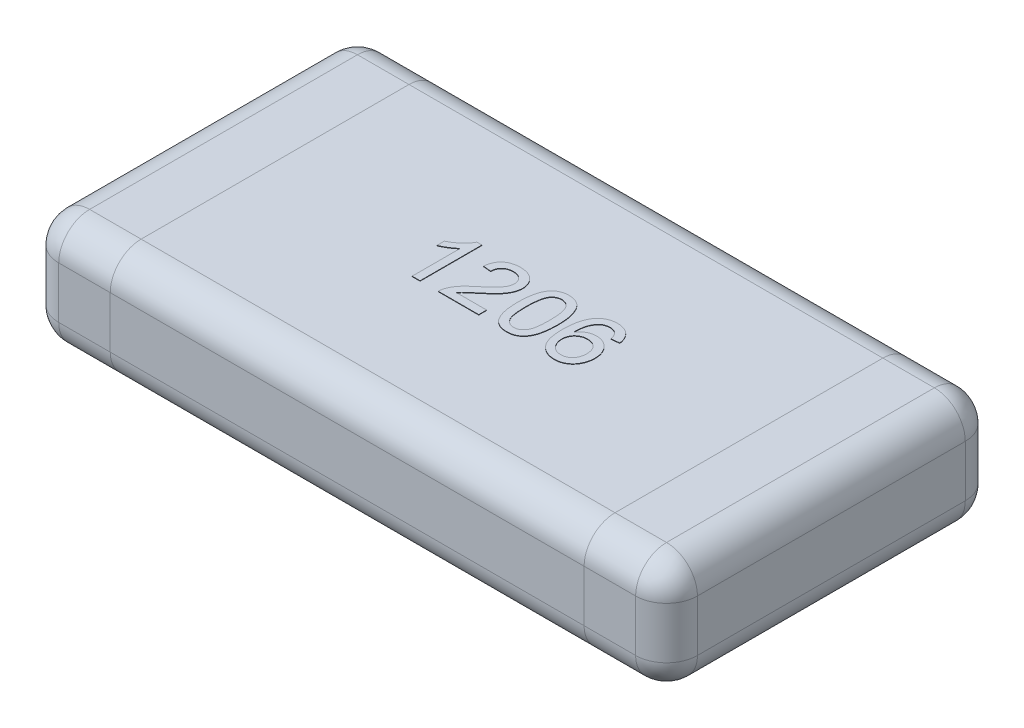
from build123d import *

# Parameters (mm, degrees)
SKETCH1_W      = 3.1
SKETCH1_H      = 1.6
EXTRUDE1_DEPTH = 0.55
FILLET1_R      = 0.15
EXTRUDE2_DEPTH = 0.002


with BuildPart() as part:
    # Sketch1 → Extrude1 (new body)
    with BuildSketch(Plane(origin=(0, 0, 0), x_dir=(1, 0, 0), z_dir=(0, 1, 0))):
        Rectangle(SKETCH1_W, SKETCH1_H)
    extrude(amount=EXTRUDE1_DEPTH)

    # Fillet1
    fillet1_edges = [part.edges().sort_by_distance(p)[0] for p in [
        (1.55, 0.55, 0),
        (0, 0.55, -0.8),
        (-1.55, 0.55, 0),
        (0, 0, -0.8),
        (1.55, 0, 0),
        (0, 0, 0.8),
        (-1.55, 0, 0),
        (0, 0.55, 0.8),
        (-1.55, 0.275, -0.8),
        (1.55, 0.275, -0.8),
        (1.55, 0.275, 0.8),
        (-1.55, 0.275, 0.8),
    ]]
    fillet(fillet1_edges, radius=FILLET1_R)

    # Sketch3 → Extrude2 (add)
    with BuildSketch(Plane(origin=(0, 0.55, 0), x_dir=(1, 0, 0), z_dir=(0, 1, 0))):
        with BuildLine():
            Line((-0.296153846, -0.15), (-0.334615385, -0.15))
            Line((-0.334615385, -0.15), (-0.334615385, 0.083774038))
            add(Edge.make_bspline(
                [(-0.334615385, 0.083774038), (-0.336830003, 0.081638311), (-0.341432846, 0.077199436), (-0.349213465, 0.070917319), (-0.35789763, 0.064550127), (-0.367372572, 0.05842736), (-0.377030672, 0.052663436), (-0.386363982, 0.047479672), (-0.39521668, 0.04309295), (-0.401047999, 0.040694273), (-0.403846154, 0.039543269)],
                knots=[0, 0, 0, 0, 9.226e-06, 1.9175e-05, 2.9969e-05, 4.1521e-05, 5.3002e-05, 6.3707e-05, 7.3544e-05, 8.2619e-05, 8.2619e-05, 8.2619e-05, 8.2619e-05], degree=3))
            Line((-0.403846154, 0.039543269), (-0.403846154, 0.075))
            add(Edge.make_bspline(
                [(-0.403846154, 0.075), (-0.399040034, 0.077475162), (-0.389567455, 0.082353558), (-0.37618475, 0.09077922), (-0.363690555, 0.099912985), (-0.352291699, 0.10975283), (-0.342073351, 0.119810917), (-0.333462201, 0.129959923), (-0.326256938, 0.139827828), (-0.322641922, 0.146709597), (-0.320913462, 0.15)],
                knots=[0, 0, 0, 0, 1.6212e-05, 3.1953e-05, 4.7386e-05, 6.26e-05, 7.7091e-05, 9.0349e-05, 0.000102505, 0.000113642, 0.000113642, 0.000113642, 0.000113642], degree=3))
            Line((-0.320913462, 0.15), (-0.296153846, 0.15))
            Line((-0.296153846, 0.15), (-0.296153846, -0.15))
        make_face()
        with BuildLine():
            Line((-0.011538462, -0.111538462), (-0.011538462, -0.15))
            Line((-0.011538462, -0.15), (-0.207692308, -0.15))
            add(Edge.make_bspline(
                [(-0.207692308, -0.15), (-0.207696323, -0.147714123), (-0.207704342, -0.14315003), (-0.206932024, -0.136400026), (-0.205722419, -0.129739566), (-0.204354719, -0.125468478), (-0.203665865, -0.123317308)],
                knots=[0, 0, 0, 0, 6.852e-06, 1.3681e-05, 2.0352e-05, 2.7121e-05, 2.7121e-05, 2.7121e-05, 2.7121e-05], degree=3))
            add(Edge.make_bspline(
                [(-0.203665865, -0.123317308), (-0.202393093, -0.119802551), (-0.199801518, -0.112645929), (-0.19455096, -0.102319922), (-0.188375063, -0.092056365), (-0.182361958, -0.08370038), (-0.176855252, -0.077024532), (-0.172237162, -0.071801454), (-0.167119471, -0.066455018), (-0.161506278, -0.060986201), (-0.155451607, -0.055359583), (-0.148947197, -0.049556401), (-0.141916239, -0.043684801), (-0.137007895, -0.039792861), (-0.134495192, -0.037800481)],
                knots=[0, 0, 0, 0, 1.1205e-05, 2.2816e-05, 3.4678e-05, 4.712e-05, 5.3653e-05, 6.0635e-05, 6.8031e-05, 7.5851e-05, 8.4142e-05, 9.2826e-05, 0.000101998, 0.000111618, 0.000111618, 0.000111618, 0.000111618], degree=3))
            add(Edge.make_bspline(
                [(-0.134495192, -0.037800481), (-0.130635061, -0.034551471), (-0.123202132, -0.028295295), (-0.112705672, -0.019011711), (-0.103118865, -0.010391377), (-0.094594368, -0.002283205), (-0.087062462, 0.005234162), (-0.080505461, 0.012143692), (-0.074866946, 0.018423822), (-0.070215752, 0.024301865), (-0.066291398, 0.029852373), (-0.062965854, 0.035266551), (-0.060194454, 0.040638972), (-0.057886249, 0.045952637), (-0.056060655, 0.05123027), (-0.054816253, 0.056487246), (-0.053972343, 0.061671403), (-0.053887909, 0.065120999), (-0.053846154, 0.066826923)],
                knots=[0, 0, 0, 0, 1.5136e-05, 2.9145e-05, 4.2036e-05, 5.3811e-05, 6.4435e-05, 7.3957e-05, 8.2386e-05, 8.9745e-05, 9.643e-05, 0.000102769, 0.00010879, 0.00011455, 0.000120137, 0.000125516, 0.000130743, 0.000135857, 0.000135857, 0.000135857, 0.000135857], degree=3))
            add(Edge.make_bspline(
                [(-0.053846154, 0.066826923), (-0.053887914, 0.068512943), (-0.053969845, 0.071820821), (-0.054747201, 0.076661881), (-0.055829343, 0.081323937), (-0.057578837, 0.085723063), (-0.059661262, 0.089989532), (-0.062332474, 0.093988532), (-0.065422517, 0.097819726), (-0.068960356, 0.101382104), (-0.072824504, 0.104724183), (-0.077142138, 0.107502263), (-0.081629679, 0.110003363), (-0.086441941, 0.11201439), (-0.091571106, 0.113491124), (-0.096979835, 0.114562852), (-0.10266727, 0.115242385), (-0.106548545, 0.115336486), (-0.108533654, 0.115384615)],
                knots=[0, 0, 0, 0, 5.054e-06, 9.915e-06, 1.4681e-05, 1.938e-05, 2.4083e-05, 2.89e-05, 3.3772e-05, 3.8829e-05, 4.3946e-05, 4.9063e-05, 5.4199e-05, 5.9345e-05, 6.4669e-05, 7.0185e-05, 7.5872e-05, 8.1827e-05, 8.1827e-05, 8.1827e-05, 8.1827e-05], degree=3))
            add(Edge.make_bspline(
                [(-0.108533654, 0.115384615), (-0.110618956, 0.115336725), (-0.114700045, 0.115242999), (-0.120665504, 0.114560756), (-0.126328674, 0.113518381), (-0.131676037, 0.111924678), (-0.136701084, 0.109917004), (-0.141383351, 0.107389877), (-0.145797819, 0.104537208), (-0.149805459, 0.101159863), (-0.153429516, 0.097415076), (-0.156646835, 0.093338135), (-0.159282944, 0.088850365), (-0.161459952, 0.084050442), (-0.163210448, 0.078923275), (-0.164481249, 0.07342967), (-0.165174098, 0.067585487), (-0.165313425, 0.063583392), (-0.165384615, 0.061538462)],
                knots=[0, 0, 0, 0, 6.255e-06, 1.2241e-05, 1.7992e-05, 2.3507e-05, 2.8953e-05, 3.4195e-05, 3.9446e-05, 4.4693e-05, 4.9878e-05, 5.506e-05, 6.0233e-05, 6.5451e-05, 7.0848e-05, 7.6461e-05, 8.2334e-05, 8.8471e-05, 8.8471e-05, 8.8471e-05, 8.8471e-05], degree=3))
            Line((-0.165384615, 0.061538462), (-0.203846154, 0.065384615))
            add(Edge.make_bspline(
                [(-0.203846154, 0.065384615), (-0.203452638, 0.068736632), (-0.202687086, 0.075257693), (-0.200780201, 0.084702351), (-0.198103106, 0.09348859), (-0.194899737, 0.101738909), (-0.190884012, 0.109312863), (-0.18634458, 0.11636711), (-0.18099053, 0.122677919), (-0.175075725, 0.128444216), (-0.168535362, 0.133525841), (-0.161430878, 0.137965346), (-0.153765522, 0.141678718), (-0.145581988, 0.144753235), (-0.136861488, 0.147085948), (-0.12761636, 0.148758724), (-0.117831734, 0.149789842), (-0.111120341, 0.149928948), (-0.107692308, 0.15)],
                knots=[0, 0, 0, 0, 1.0123e-05, 1.9693e-05, 2.8857e-05, 3.7651e-05, 4.6199e-05, 5.4533e-05, 6.2766e-05, 7.0968e-05, 7.9275e-05, 8.7563e-05, 9.6056e-05, 0.000104785, 0.00011375, 0.000123098, 0.000132946, 0.000143229, 0.000143229, 0.000143229, 0.000143229], degree=3))
            add(Edge.make_bspline(
                [(-0.107692308, 0.15), (-0.104223243, 0.149940596), (-0.097465484, 0.149824877), (-0.087618344, 0.14864084), (-0.078327294, 0.146796713), (-0.069558275, 0.144226564), (-0.061363096, 0.140856333), (-0.053735451, 0.136738671), (-0.046640172, 0.131913745), (-0.040195807, 0.126323636), (-0.034384754, 0.120221095), (-0.029292223, 0.113708369), (-0.025034622, 0.106813279), (-0.021409539, 0.09962981), (-0.018720681, 0.092006182), (-0.016829827, 0.084046037), (-0.015544936, 0.075742575), (-0.015438766, 0.070077103), (-0.015384615, 0.0671875)],
                knots=[0, 0, 0, 0, 1.0403e-05, 2.0265e-05, 2.9705e-05, 3.8794e-05, 4.7633e-05, 5.6238e-05, 6.4755e-05, 7.3321e-05, 8.178e-05, 9.0002e-05, 9.8073e-05, 0.000106055, 0.000114096, 0.000122258, 0.000130579, 0.00013924, 0.00013924, 0.00013924, 0.00013924], degree=3))
            add(Edge.make_bspline(
                [(-0.015384615, 0.0671875), (-0.015467303, 0.06421876), (-0.01563286, 0.058274728), (-0.016925056, 0.049390154), (-0.019136019, 0.040601997), (-0.022067165, 0.0318033), (-0.026071721, 0.022959142), (-0.031130797, 0.013947517), (-0.037407134, 0.004735138), (-0.04344321, -0.003096409), (-0.049061817, -0.009661219), (-0.054042181, -0.015064442), (-0.059804175, -0.020805005), (-0.066131643, -0.027081717), (-0.073282651, -0.033671804), (-0.081051734, -0.040772611), (-0.089608959, -0.048197271), (-0.095549342, -0.053269443), (-0.098617788, -0.055889423)],
                knots=[0, 0, 0, 0, 8.904e-06, 1.7828e-05, 2.6865e-05, 3.6063e-05, 4.5612e-05, 5.5944e-05, 6.7028e-05, 7.9024e-05, 8.5588e-05, 9.2946e-05, 0.000101063, 0.000109987, 0.000119681, 0.000130232, 0.000141562, 0.000153666, 0.000153666, 0.000153666, 0.000153666], degree=3))
            add(Edge.make_bspline(
                [(-0.098617788, -0.055889423), (-0.101245449, -0.058028619), (-0.106255994, -0.062107737), (-0.113384465, -0.068021343), (-0.119769407, -0.07344396), (-0.12556013, -0.078198712), (-0.130545741, -0.08251558), (-0.13490185, -0.086205504), (-0.138470198, -0.089454013), (-0.14390416, -0.094388563), (-0.150786737, -0.101422266), (-0.155858114, -0.108256719), (-0.158293269, -0.111538462)],
                knots=[0, 0, 0, 0, 1.0165e-05, 1.9383e-05, 2.7786e-05, 3.5295e-05, 4.1859e-05, 4.7569e-05, 5.242e-05, 5.6334e-05, 6.9594e-05, 8.1844e-05, 8.1844e-05, 8.1844e-05, 8.1844e-05], degree=3))
            Line((-0.158293269, -0.111538462), (-0.011538462, -0.111538462))
        make_face()
        with BuildLine():
            add(Edge.make_bspline(
                [(0.030769231, -0.002043269), (0.030807981, 0.002244006), (0.030883876, 0.010640973), (0.031354627, 0.022927244), (0.032176522, 0.034595007), (0.033403384, 0.045634129), (0.034856218, 0.056069528), (0.036744912, 0.06588631), (0.038869967, 0.075106502), (0.041419652, 0.083720493), (0.044220921, 0.091802347), (0.047399051, 0.0993391), (0.050974877, 0.106322761), (0.054772671, 0.112825754), (0.058992356, 0.118746931), (0.063379241, 0.124252464), (0.068252138, 0.129140445), (0.073408422, 0.13353664), (0.07892402, 0.137416027), (0.084769749, 0.140763469), (0.090923117, 0.143719019), (0.097501399, 0.145943957), (0.104368033, 0.147757753), (0.111575873, 0.149092003), (0.119132863, 0.149878588), (0.124297003, 0.149959072), (0.126923077, 0.15)],
                knots=[0, 0, 0, 0, 1.2862e-05, 2.5191e-05, 3.688e-05, 4.7943e-05, 5.8507e-05, 6.8478e-05, 7.7924e-05, 8.6881e-05, 9.5415e-05, 0.000103574, 0.000111395, 0.00011894, 0.000126142, 0.000133191, 0.000140033, 0.000146812, 0.000153498, 0.000160229, 0.000167003, 0.000173941, 0.000181025, 0.000188297, 0.00019591, 0.000203786, 0.000203786, 0.000203786, 0.000203786], degree=3))
            add(Edge.make_bspline(
                [(0.126923077, 0.15), (0.130775868, 0.149886731), (0.138344831, 0.149664209), (0.149395556, 0.147849358), (0.159810153, 0.144744777), (0.169581854, 0.140556563), (0.178543614, 0.135236725), (0.186546843, 0.128769652), (0.193505214, 0.121223246), (0.199342787, 0.112508085), (0.204445409, 0.102864591), (0.208978466, 0.092249481), (0.213076217, 0.080674651), (0.215984071, 0.070313561), (0.218058241, 0.061369501), (0.219431176, 0.053992694), (0.220570988, 0.046033077), (0.221444238, 0.037509907), (0.222160719, 0.028432744), (0.222714024, 0.018795935), (0.222994883, 0.008575397), (0.223049064, 0.001562641), (0.223076923, -0.002043269)],
                knots=[0, 0, 0, 0, 1.1554e-05, 2.2698e-05, 3.348e-05, 4.4085e-05, 5.4516e-05, 6.4643e-05, 7.485e-05, 8.5185e-05, 9.602e-05, 0.000107541, 0.000119781, 0.000132832, 0.000139801, 0.000147321, 0.000155335, 0.000163916, 0.000173019, 0.00018265, 0.000192871, 0.000203689, 0.000203689, 0.000203689, 0.000203689], degree=3))
            add(Edge.make_bspline(
                [(0.223076923, -0.002043269), (0.223037447, -0.006310407), (0.222960323, -0.0146471), (0.222502186, -0.026834856), (0.221630766, -0.038414591), (0.220558469, -0.049412832), (0.218936308, -0.059800218), (0.217188341, -0.069620882), (0.215026538, -0.07883023), (0.212504222, -0.087432298), (0.209663521, -0.095472571), (0.206548253, -0.103011813), (0.203097794, -0.110044871), (0.199209446, -0.11650315), (0.195061119, -0.122472371), (0.190622429, -0.127974928), (0.185799273, -0.132931621), (0.180596523, -0.137314631), (0.175119652, -0.141262812), (0.16925971, -0.144643304), (0.163042348, -0.147443983), (0.156509104, -0.149838424), (0.149593689, -0.15159293), (0.142350639, -0.152935977), (0.134753266, -0.153726861), (0.129569151, -0.153805841), (0.126923077, -0.153846154)],
                knots=[0, 0, 0, 0, 1.2802e-05, 2.5011e-05, 3.658e-05, 4.7637e-05, 5.815e-05, 6.811e-05, 7.7556e-05, 8.6513e-05, 9.499e-05, 0.000103126, 0.000110974, 0.000118467, 0.000125719, 0.000132767, 0.000139652, 0.000146431, 0.000153152, 0.000159883, 0.000166686, 0.000173587, 0.000180729, 0.000188061, 0.000195673, 0.00020361, 0.00020361, 0.00020361, 0.00020361], degree=3))
            add(Edge.make_bspline(
                [(0.126923077, -0.153846154), (0.123453767, -0.153747192), (0.116689568, -0.153554242), (0.106810954, -0.152243272), (0.097539347, -0.149935902), (0.088796548, -0.146841394), (0.080680827, -0.142702311), (0.073153436, -0.137666308), (0.066063116, -0.131850554), (0.061981497, -0.127262057), (0.059915865, -0.124939904)],
                knots=[0, 0, 0, 0, 1.0408e-05, 2.0292e-05, 2.9825e-05, 3.9025e-05, 4.8056e-05, 5.7073e-05, 6.616e-05, 7.5471e-05, 7.5471e-05, 7.5471e-05, 7.5471e-05], degree=3))
            add(Edge.make_bspline(
                [(0.059915865, -0.124939904), (0.057538275, -0.121510195), (0.052635583, -0.11443799), (0.046897407, -0.102379223), (0.041778852, -0.089104214), (0.037761725, -0.074352508), (0.034615313, -0.058241513), (0.032342818, -0.040739616), (0.031056809, -0.021854376), (0.030867254, -0.008796046), (0.030769231, -0.002043269)],
                knots=[0, 0, 0, 0, 1.2501e-05, 2.5778e-05, 3.993e-05, 5.5152e-05, 7.157e-05, 8.9147e-05, 0.000108063, 0.000128321, 0.000128321, 0.000128321, 0.000128321], degree=3))
        make_face()
        with BuildLine():
            add(Edge.make_bspline(
                [(0.069230769, -0.001923077), (0.069268958, -0.007693168), (0.069342061, -0.018738399), (0.070105807, -0.034518417), (0.071420563, -0.048754147), (0.073158757, -0.061425879), (0.075453876, -0.072550754), (0.07833567, -0.082100422), (0.081584138, -0.090189501), (0.085604055, -0.096717734), (0.090005419, -0.102039196), (0.094549528, -0.106615825), (0.099343287, -0.110505855), (0.104355418, -0.113749347), (0.109663688, -0.116205105), (0.115210052, -0.117985045), (0.120995717, -0.119009373), (0.124936017, -0.119156549), (0.126923077, -0.119230769)],
                knots=[0, 0, 0, 0, 1.7309e-05, 3.3134e-05, 4.7378e-05, 6.0186e-05, 7.1489e-05, 8.1413e-05, 9.0085e-05, 9.7558e-05, 0.000104306, 0.000110765, 0.000116876, 0.000122794, 0.000128628, 0.000134368, 0.000140227, 0.000146187, 0.000146187, 0.000146187, 0.000146187], degree=3))
            add(Edge.make_bspline(
                [(0.126923077, -0.119230769), (0.128909639, -0.119154928), (0.132848953, -0.119004535), (0.138647986, -0.118002795), (0.14417277, -0.116131225), (0.149473125, -0.11368414), (0.154521686, -0.110514577), (0.159291902, -0.106609854), (0.163859948, -0.102035942), (0.168241542, -0.096652628), (0.172230832, -0.090094213), (0.175540237, -0.082011723), (0.17837712, -0.072445331), (0.180684833, -0.061326124), (0.182430197, -0.048674427), (0.183737005, -0.03447818), (0.184505861, -0.018718466), (0.184577757, -0.007693194), (0.184615385, -0.001923077)],
                knots=[0, 0, 0, 0, 5.96e-06, 1.1819e-05, 1.7578e-05, 2.3412e-05, 2.9298e-05, 3.5408e-05, 4.1867e-05, 4.8662e-05, 5.6186e-05, 6.4803e-05, 7.4784e-05, 8.6088e-05, 9.8836e-05, 0.00011308, 0.000128845, 0.000146154, 0.000146154, 0.000146154, 0.000146154], degree=3))
            add(Edge.make_bspline(
                [(0.184615385, -0.001923077), (0.184578962, 0.003726983), (0.184509178, 0.014552283), (0.183720492, 0.030028299), (0.182484549, 0.044025088), (0.180793976, 0.056555555), (0.178547205, 0.067606095), (0.175822177, 0.077200235), (0.1725749, 0.085317512), (0.168713899, 0.092039466), (0.164415832, 0.097553292), (0.159926094, 0.102325988), (0.15513244, 0.10638501), (0.149949942, 0.109641218), (0.144545641, 0.112268205), (0.13879536, 0.114076165), (0.13275562, 0.115186918), (0.128610625, 0.115317963), (0.126502404, 0.115384615)],
                knots=[0, 0, 0, 0, 1.6949e-05, 3.2473e-05, 4.6473e-05, 5.9094e-05, 7.0385e-05, 8.0274e-05, 8.8979e-05, 9.6545e-05, 0.000103444, 0.000109906, 0.000116177, 0.000122229, 0.000128223, 0.000134153, 0.000140259, 0.000146579, 0.000146579, 0.000146579, 0.000146579], degree=3))
            add(Edge.make_bspline(
                [(0.126502404, 0.115384615), (0.124515469, 0.115332466), (0.120597487, 0.115229635), (0.114861049, 0.114248109), (0.109424694, 0.112606778), (0.104226139, 0.110383437), (0.099395163, 0.107391258), (0.094740182, 0.103897677), (0.090479217, 0.099641138), (0.087911597, 0.096459016), (0.086598558, 0.094831731)],
                knots=[0, 0, 0, 0, 5.957e-06, 1.1747e-05, 1.7393e-05, 2.2965e-05, 2.8654e-05, 3.4399e-05, 4.0391e-05, 4.6662e-05, 4.6662e-05, 4.6662e-05, 4.6662e-05], degree=3))
            add(Edge.make_bspline(
                [(0.086598558, 0.094831731), (0.085169059, 0.092441753), (0.082150258, 0.087394622), (0.078772395, 0.078622501), (0.075788524, 0.068597636), (0.07333181, 0.057165788), (0.071554549, 0.044346567), (0.07015147, 0.03015486), (0.069422623, 0.014570853), (0.069296485, 0.003726591), (0.069230769, -0.001923077)],
                knots=[0, 0, 0, 0, 8.341e-06, 1.7615e-05, 2.8091e-05, 3.9714e-05, 5.2649e-05, 6.6899e-05, 8.2483e-05, 9.9433e-05, 9.9433e-05, 9.9433e-05, 9.9433e-05], degree=3))
        make_face(mode=Mode.SUBTRACT)
        with BuildLine():
            Line((0.45, 0.073076923), (0.411538462, 0.069230769))
            add(Edge.make_bspline(
                [(0.411538462, 0.069230769), (0.410708492, 0.072538667), (0.409146203, 0.078765275), (0.405870098, 0.087210729), (0.4022599, 0.094354147), (0.399123422, 0.09820068), (0.39765625, 0.1)],
                knots=[0, 0, 0, 0, 1.022e-05, 1.9238e-05, 2.7142e-05, 3.4089e-05, 3.4089e-05, 3.4089e-05, 3.4089e-05], degree=3))
            add(Edge.make_bspline(
                [(0.39765625, 0.1), (0.396396853, 0.101227235), (0.393919912, 0.103640922), (0.389853676, 0.10678718), (0.385567189, 0.109452847), (0.381047498, 0.111612442), (0.376319018, 0.113318398), (0.371362165, 0.114511805), (0.366188166, 0.115250592), (0.362662732, 0.115339561), (0.360877404, 0.115384615)],
                knots=[0, 0, 0, 0, 5.272e-06, 1.0369e-05, 1.5389e-05, 2.0388e-05, 2.5369e-05, 3.0441e-05, 3.5659e-05, 4.1013e-05, 4.1013e-05, 4.1013e-05, 4.1013e-05], degree=3))
            add(Edge.make_bspline(
                [(0.360877404, 0.115384615), (0.357983079, 0.115291422), (0.352264021, 0.115107275), (0.343873139, 0.113304494), (0.335723235, 0.110606344), (0.330674068, 0.107871213), (0.328125, 0.106490385)],
                knots=[0, 0, 0, 0, 8.671e-06, 1.7133e-05, 2.5647e-05, 3.4328e-05, 3.4328e-05, 3.4328e-05, 3.4328e-05], degree=3))
            add(Edge.make_bspline(
                [(0.328125, 0.106490385), (0.32561815, 0.104413394), (0.320472186, 0.10014983), (0.313756639, 0.092271657), (0.307751014, 0.08309911), (0.303321758, 0.074535839), (0.300204588, 0.066858114), (0.298188572, 0.060278069), (0.296466137, 0.053008475), (0.295031251, 0.045063026), (0.29392146, 0.036435278), (0.292993896, 0.027119753), (0.292480875, 0.017092829), (0.292366611, 0.010176786), (0.292307692, 0.006610577)],
                knots=[0, 0, 0, 0, 9.752e-06, 2.0019e-05, 3.0903e-05, 4.2594e-05, 4.8877e-05, 5.5739e-05, 6.3217e-05, 7.1279e-05, 7.9949e-05, 8.9307e-05, 9.9358e-05, 0.000110058, 0.000110058, 0.000110058, 0.000110058], degree=3))
            add(Edge.make_bspline(
                [(0.292307692, 0.006610577), (0.294575255, 0.009796435), (0.299014148, 0.016032946), (0.30684469, 0.024190765), (0.31539528, 0.031086712), (0.324675478, 0.036592663), (0.334443135, 0.040859911), (0.344482862, 0.04393058), (0.354777063, 0.045815439), (0.3617109, 0.04604047), (0.365204327, 0.046153846)],
                knots=[0, 0, 0, 0, 1.1719e-05, 2.294e-05, 3.3799e-05, 4.458e-05, 5.5209e-05, 6.5703e-05, 7.6018e-05, 8.6492e-05, 8.6492e-05, 8.6492e-05, 8.6492e-05], degree=3))
            add(Edge.make_bspline(
                [(0.365204327, 0.046153846), (0.368213024, 0.046072896), (0.374157277, 0.045912965), (0.382910862, 0.044645582), (0.391302971, 0.042428842), (0.399406328, 0.03954103), (0.407065214, 0.035598019), (0.414466549, 0.0309898), (0.421438918, 0.025382127), (0.428070563, 0.019081266), (0.434108418, 0.012076111), (0.439452347, 0.004536569), (0.443905634, -0.003555431), (0.447516735, -0.012145696), (0.450343053, -0.021202968), (0.452396708, -0.030752967), (0.45359889, -0.040814567), (0.453762628, -0.047693081), (0.453846154, -0.051201923)],
                knots=[0, 0, 0, 0, 9.024e-06, 1.7829e-05, 2.6458e-05, 3.5032e-05, 4.3579e-05, 5.2249e-05, 6.1146e-05, 7.037e-05, 7.9659e-05, 8.8846e-05, 9.8045e-05, 0.000107309, 0.000116756, 0.000126468, 0.000136576, 0.000147101, 0.000147101, 0.000147101, 0.000147101], degree=3))
            add(Edge.make_bspline(
                [(0.453846154, -0.051201923), (0.453696506, -0.055839129), (0.453401179, -0.064990544), (0.45103072, -0.078467226), (0.447211078, -0.091457445), (0.442641819, -0.101744572), (0.438443862, -0.109625611), (0.434879306, -0.115137959), (0.431067791, -0.120318178), (0.427081512, -0.12523755), (0.422631343, -0.129670926), (0.417987077, -0.133827203), (0.412995205, -0.137562688), (0.407802543, -0.141001671), (0.402310998, -0.143983621), (0.396680359, -0.146633405), (0.390864275, -0.148890534), (0.384843967, -0.150662761), (0.378650268, -0.152128961), (0.372262562, -0.153137108), (0.365697661, -0.153758859), (0.361259417, -0.15381683), (0.359014423, -0.153846154)],
                knots=[0, 0, 0, 0, 1.3904e-05, 2.744e-05, 4.0921e-05, 5.443e-05, 6.1126e-05, 6.7694e-05, 7.4101e-05, 8.0418e-05, 8.6665e-05, 9.2923e-05, 9.9101e-05, 0.000105352, 0.000111591, 0.000117829, 0.000124012, 0.000130286, 0.000136642, 0.000143093, 0.000149671, 0.000156404, 0.000156404, 0.000156404, 0.000156404], degree=3))
            add(Edge.make_bspline(
                [(0.359014423, -0.153846154), (0.355223048, -0.153741017), (0.347787494, -0.153534825), (0.336904474, -0.151950766), (0.32657057, -0.14930358), (0.316763801, -0.145602515), (0.307454292, -0.140929997), (0.298733786, -0.135072673), (0.290554031, -0.128204222), (0.28290872, -0.120284809), (0.275976723, -0.11114027), (0.270052326, -0.100584666), (0.265004214, -0.088710395), (0.260872774, -0.075484787), (0.257746467, -0.060894011), (0.255495393, -0.044969404), (0.254111008, -0.027708685), (0.253936503, -0.015747884), (0.253846154, -0.009555288)],
                knots=[0, 0, 0, 0, 1.1371e-05, 2.2301e-05, 3.2912e-05, 4.3315e-05, 5.3689e-05, 6.409e-05, 7.4754e-05, 8.5677e-05, 9.7048e-05, 0.000109078, 0.000121893, 0.000135692, 0.00015058, 0.000166609, 0.000183912, 0.000202488, 0.000202488, 0.000202488, 0.000202488], degree=3))
            add(Edge.make_bspline(
                [(0.253846154, -0.009555288), (0.253861135, -0.006029025), (0.253890683, 0.000925972), (0.25436549, 0.011161994), (0.254910152, 0.021047347), (0.255843344, 0.030542594), (0.256945199, 0.039690441), (0.258423875, 0.048437091), (0.260011794, 0.056850531), (0.26194238, 0.06486452), (0.264094511, 0.072554447), (0.266571688, 0.079835817), (0.269188202, 0.086802839), (0.272156581, 0.093345608), (0.275320183, 0.099570683), (0.278817081, 0.105362867), (0.282484377, 0.1108546), (0.285191728, 0.114240976), (0.286538462, 0.115925481)],
                knots=[0, 0, 0, 0, 1.0578e-05, 2.0863e-05, 3.0737e-05, 4.0275e-05, 4.948e-05, 5.8372e-05, 6.6882e-05, 7.5161e-05, 8.3094e-05, 9.0829e-05, 9.8228e-05, 0.00010541, 0.000112371, 0.000119163, 0.000125697, 0.000132165, 0.000132165, 0.000132165, 0.000132165], degree=3))
            add(Edge.make_bspline(
                [(0.286538462, 0.115925481), (0.288961211, 0.118650597), (0.293736676, 0.124022054), (0.301905995, 0.130960705), (0.310611092, 0.136887379), (0.319990804, 0.14167562), (0.32997344, 0.145408685), (0.340565259, 0.14811856), (0.351795817, 0.149690101), (0.359470198, 0.149895026), (0.363401442, 0.15)],
                knots=[0, 0, 0, 0, 1.0928e-05, 2.154e-05, 3.2057e-05, 4.2459e-05, 5.3051e-05, 6.3969e-05, 7.5196e-05, 8.6987e-05, 8.6987e-05, 8.6987e-05, 8.6987e-05], degree=3))
            add(Edge.make_bspline(
                [(0.363401442, 0.15), (0.36632869, 0.149948255), (0.372079505, 0.149846599), (0.380505916, 0.148871193), (0.388520914, 0.147240948), (0.39614235, 0.145041931), (0.403325908, 0.142114758), (0.410154404, 0.138645741), (0.416558502, 0.134472732), (0.422491839, 0.129652743), (0.427969112, 0.124322407), (0.432875029, 0.118436964), (0.437191105, 0.112069766), (0.440951092, 0.10520757), (0.444121392, 0.097882861), (0.446724366, 0.090064157), (0.4487028, 0.081753468), (0.449561606, 0.076009194), (0.45, 0.073076923)],
                knots=[0, 0, 0, 0, 8.779e-06, 1.7247e-05, 2.5403e-05, 3.3295e-05, 4.1006e-05, 4.864e-05, 5.624e-05, 6.389e-05, 7.1539e-05, 7.9134e-05, 8.6834e-05, 9.458e-05, 0.000102574, 0.000110746, 0.000119273, 0.000128165, 0.000128165, 0.000128165, 0.000128165], degree=3))
        make_face()
        with BuildLine():
            add(Edge.make_bspline(
                [(0.292307692, -0.050420673), (0.292414672, -0.053432194), (0.292627226, -0.0594157), (0.294253022, -0.068297189), (0.296908061, -0.076962701), (0.300546824, -0.085315996), (0.305040025, -0.093077055), (0.310376901, -0.099953889), (0.316441609, -0.105845529), (0.323201556, -0.110764759), (0.330640875, -0.114545052), (0.338626325, -0.117282967), (0.347167448, -0.118937772), (0.353057469, -0.119131628), (0.356069712, -0.119230769)],
                knots=[0, 0, 0, 0, 9.031e-06, 1.7943e-05, 2.6992e-05, 3.6169e-05, 4.5219e-05, 5.3826e-05, 6.2198e-05, 7.0505e-05, 7.881e-05, 8.7134e-05, 9.5761e-05, 0.000104792, 0.000104792, 0.000104792, 0.000104792], degree=3))
            add(Edge.make_bspline(
                [(0.356069712, -0.119230769), (0.358216277, -0.119172715), (0.362406182, -0.1190594), (0.368540884, -0.118181315), (0.374394068, -0.116831083), (0.379931842, -0.114836124), (0.38514669, -0.112290008), (0.390065691, -0.109191217), (0.394685661, -0.105530475), (0.398950744, -0.1013145), (0.402805456, -0.096625578), (0.406154689, -0.091492483), (0.409112375, -0.085999667), (0.411337027, -0.080012147), (0.413149797, -0.073683317), (0.414482528, -0.066953335), (0.415264982, -0.059814476), (0.41534416, -0.05490983), (0.415384615, -0.052403846)],
                knots=[0, 0, 0, 0, 6.437e-06, 1.2565e-05, 1.8556e-05, 2.443e-05, 3.0181e-05, 3.5934e-05, 4.1837e-05, 4.7829e-05, 5.3893e-05, 6.001e-05, 6.6193e-05, 7.2565e-05, 7.9128e-05, 8.5928e-05, 9.3122e-05, 0.000100638, 0.000100638, 0.000100638, 0.000100638], degree=3))
            add(Edge.make_bspline(
                [(0.415384615, -0.052403846), (0.415347094, -0.049997387), (0.415273715, -0.045291251), (0.414448055, -0.038423999), (0.413245266, -0.031932012), (0.411398846, -0.025869914), (0.409132681, -0.020173529), (0.406293201, -0.014885466), (0.40298467, -0.009960784), (0.399105553, -0.005529883), (0.394863462, -0.001493073), (0.390204523, 0.002013282), (0.38518465, 0.00497459), (0.379785734, 0.007398919), (0.373997604, 0.009256882), (0.367832247, 0.010544495), (0.361324353, 0.011443306), (0.356854182, 0.011506257), (0.354567308, 0.011538462)],
                knots=[0, 0, 0, 0, 7.216e-06, 1.4111e-05, 2.0723e-05, 2.6997e-05, 3.309e-05, 3.9086e-05, 4.497e-05, 5.0849e-05, 5.6716e-05, 6.2509e-05, 6.8302e-05, 7.4165e-05, 8.0228e-05, 8.6499e-05, 9.3043e-05, 9.9899e-05, 9.9899e-05, 9.9899e-05, 9.9899e-05], degree=3))
            add(Edge.make_bspline(
                [(0.354567308, 0.011538462), (0.352440511, 0.011505232), (0.348249457, 0.01143975), (0.342103239, 0.010533926), (0.336179534, 0.009243732), (0.330501992, 0.007366681), (0.325068659, 0.004949397), (0.319880741, 0.002009058), (0.314983289, -0.001538568), (0.310331648, -0.005511501), (0.306087081, -0.009924881), (0.302363096, -0.014699634), (0.299325657, -0.019866478), (0.296670442, -0.02529901), (0.294725059, -0.031125292), (0.293340895, -0.03726721), (0.292482748, -0.0437259), (0.292366952, -0.048154362), (0.292307692, -0.050420673)],
                knots=[0, 0, 0, 0, 6.375e-06, 1.2562e-05, 1.8598e-05, 2.4546e-05, 3.0465e-05, 3.6413e-05, 4.24e-05, 4.858e-05, 5.4743e-05, 6.0741e-05, 6.6698e-05, 7.2692e-05, 7.885e-05, 8.5075e-05, 9.156e-05, 9.8358e-05, 9.8358e-05, 9.8358e-05, 9.8358e-05], degree=3))
        make_face(mode=Mode.SUBTRACT)
    extrude(amount=EXTRUDE2_DEPTH)


solid = part.part
